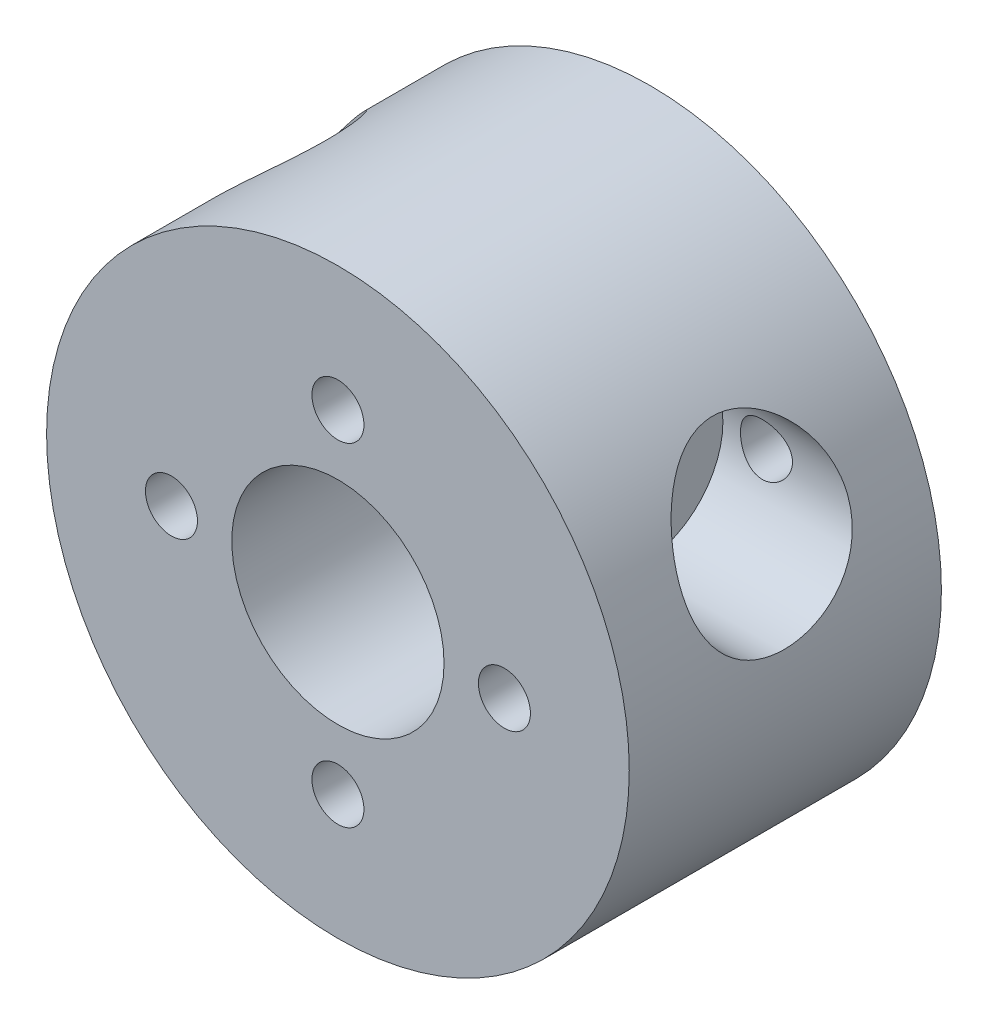
from build123d import *

# Parameters (mm, degrees)
SKETCH1_R             = 14
SKETCH1_R_2           = 5.1
BOSS_EXTRUDE1_DEPTH   = 15
M3_TAPPED_HOLE1_D     = 2.5
M3_TAPPED_HOLE1_DEPTH = 6.5
M3_TAPPED_HOLE1_TIP   = 0.751075774
M3_TAPPED_HOLE2_D     = 2.5
M3_TAPPED_HOLE2_DEPTH = 6.5
M3_TAPPED_HOLE2_TIP   = 0.751075774
SKETCH19_R            = 4
CUT_EXTRUDE3_DEPTH    = 7
CIRPATTERN2_COUNT     = 3


with BuildPart() as part:
    # Sketch1 → Boss-Extrude1 (new body)
    with BuildSketch(Plane.XY):
        Circle(SKETCH1_R)
        Circle(SKETCH1_R_2, mode=Mode.SUBTRACT)
    extrude(amount=BOSS_EXTRUDE1_DEPTH)

    # M3 Tapped Hole1
    with Locations(Plane.XY.offset(15)):
        with Locations((0, -8), (-8, 0), (0, 8), (8, 0)):
            Hole(M3_TAPPED_HOLE1_D / 2, depth=M3_TAPPED_HOLE1_DEPTH)
            with Locations((0, 0, -(M3_TAPPED_HOLE1_DEPTH + M3_TAPPED_HOLE1_TIP / 2))):  # 118° drill point
                Cone(0, M3_TAPPED_HOLE1_D / 2, M3_TAPPED_HOLE1_TIP, mode=Mode.SUBTRACT)

    # M3 Tapped Hole2
    with Locations(Plane(origin=(0, 0, 0), x_dir=(-1, 0, 0), z_dir=(0, 0, -1))):
        with Locations((0, -10.5), (-9.09326674, 5.25), (9.09326674, 5.25)):
            Hole(M3_TAPPED_HOLE2_D / 2, depth=M3_TAPPED_HOLE2_DEPTH)
            with Locations((0, 0, -(M3_TAPPED_HOLE2_DEPTH + M3_TAPPED_HOLE2_TIP / 2))):  # 118° drill point
                Cone(0, M3_TAPPED_HOLE2_D / 2, M3_TAPPED_HOLE2_TIP, mode=Mode.SUBTRACT)

    # Sketch19 → Cut-Extrude3 (cut)
    with BuildSketch(Plane(origin=(14, 0, 0), x_dir=(0, 0, -1), z_dir=(1, 0, 0))):
        with Locations((-7.5, 5.25)):
            Circle(SKETCH19_R)
    cut_extrude3 = extrude(amount=-CUT_EXTRUDE3_DEPTH, mode=Mode.SUBTRACT)

    # CirPattern2: Cut-Extrude3 ×3 about axis
    cirpattern2_axis = Axis((0, 0, 0), (0, 0, 1))
    for i in range(1, CIRPATTERN2_COUNT):
        add(cut_extrude3.rotate(cirpattern2_axis, i * 360 / CIRPATTERN2_COUNT), mode=Mode.SUBTRACT)


solid = part.part
